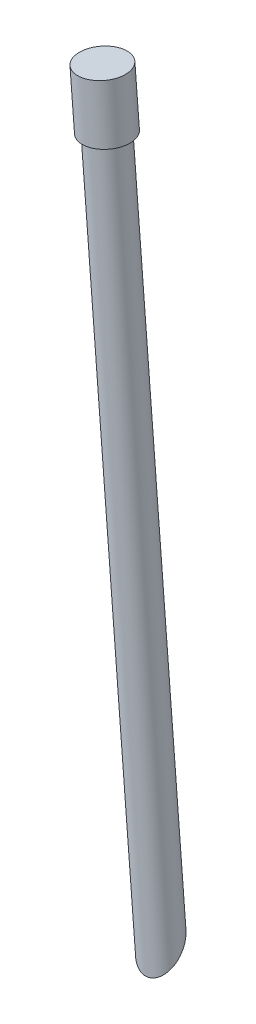
from build123d import *


with BuildPart() as part:
    # 草图1 → 旋转1 (revolve)
    with BuildSketch(Plane.XY):
        Polygon((3.050233699, 255.390679145), (5.031388725, 255.548486971), (5.425312632, 250.603077414), (5.0261176, 250.603077414), (9.960700437, 188.653211812), (8.376223588, 188.52700117), align=None)
    revolve(axis=Axis((2.315013939, 264.620793788, 0), (0.079402955, -0.996842601, 0)))

    # 草图2 → 切除-旋转1 (revolve, cut)
    with BuildSketch(Plane(origin=(0, 0, 0), x_dir=(0, 0, -1), z_dir=(1, 0, 0))):
        with BuildLine():
            Line((47.290942282, 71.880931487), (47.290942282, 211.279623848))
            ThreePointArc((47.290942282, 211.279623848), (-22.408403898, 141.580277667), (47.290942282, 71.880931487))
        make_face()
    revolve(axis=Axis((0, 235.002351216, -47.290942282), (0, -1, 0)), mode=Mode.SUBTRACT)


solid = part.part
